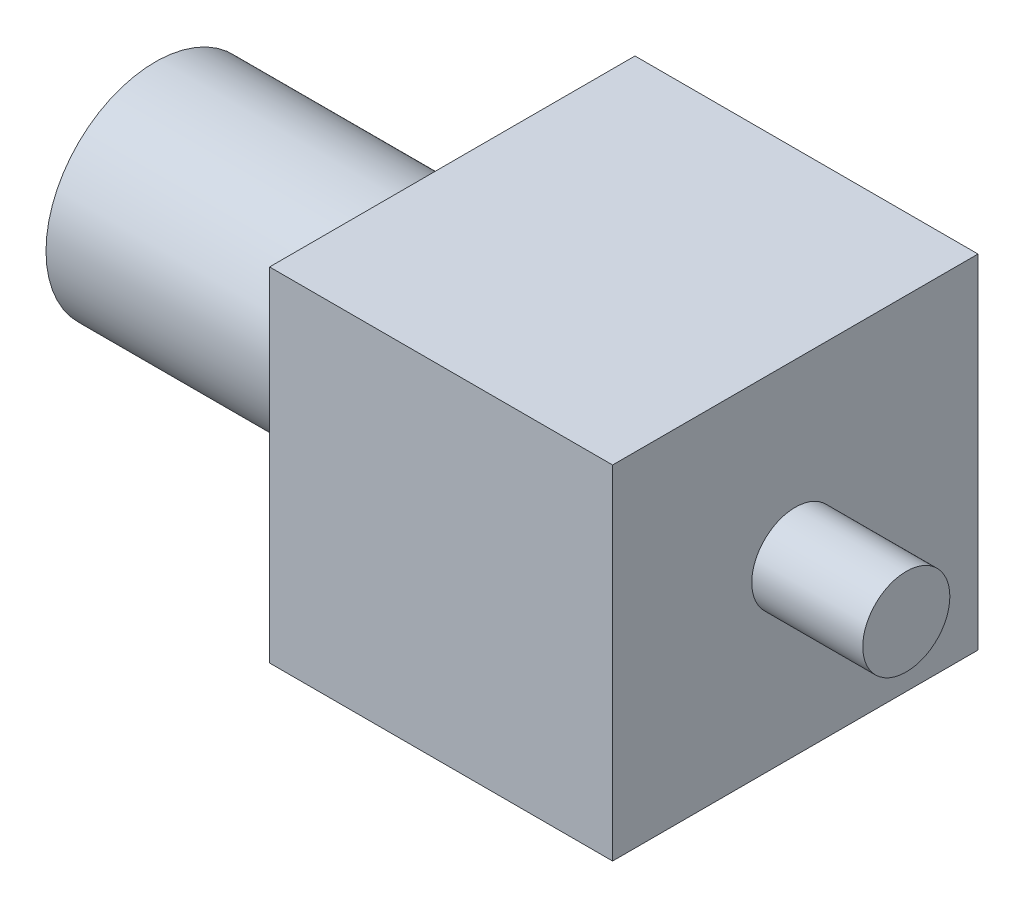
from build123d import *

# Parameters (mm, degrees)
SKETCH1_W           = 25
SKETCH1_H           = 25
BOSS_EXTRUDE1_DEPTH = 26.6319
SKETCH2_R           = 7.96925
BOSS_EXTRUDE2_DEPTH = 21.6408
SKETCH3_R           = 3.175
BOSS_EXTRUDE3_DEPTH = 8.0899


with BuildPart() as part:
    # Sketch1 → Boss-Extrude1 (new body)
    with BuildSketch(Plane.XY):
        with Locations((12.5, 12.5)):
            Rectangle(SKETCH1_W, SKETCH1_H)
    extrude(amount=BOSS_EXTRUDE1_DEPTH)

    # Sketch2 → Boss-Extrude2 (add)
    with BuildSketch(Plane.ZY):
        with Locations((13.31595, 12.5)):
            Circle(SKETCH2_R)
    extrude(amount=BOSS_EXTRUDE2_DEPTH)

    # Sketch3 → Boss-Extrude3 (add)
    with BuildSketch(Plane(origin=(25, 0, 0), x_dir=(0, 0, -1), z_dir=(1, 0, 0))):
        with Locations((-13.31595, 12.5)):
            Circle(SKETCH3_R)
    extrude(amount=BOSS_EXTRUDE3_DEPTH)


solid = part.part
